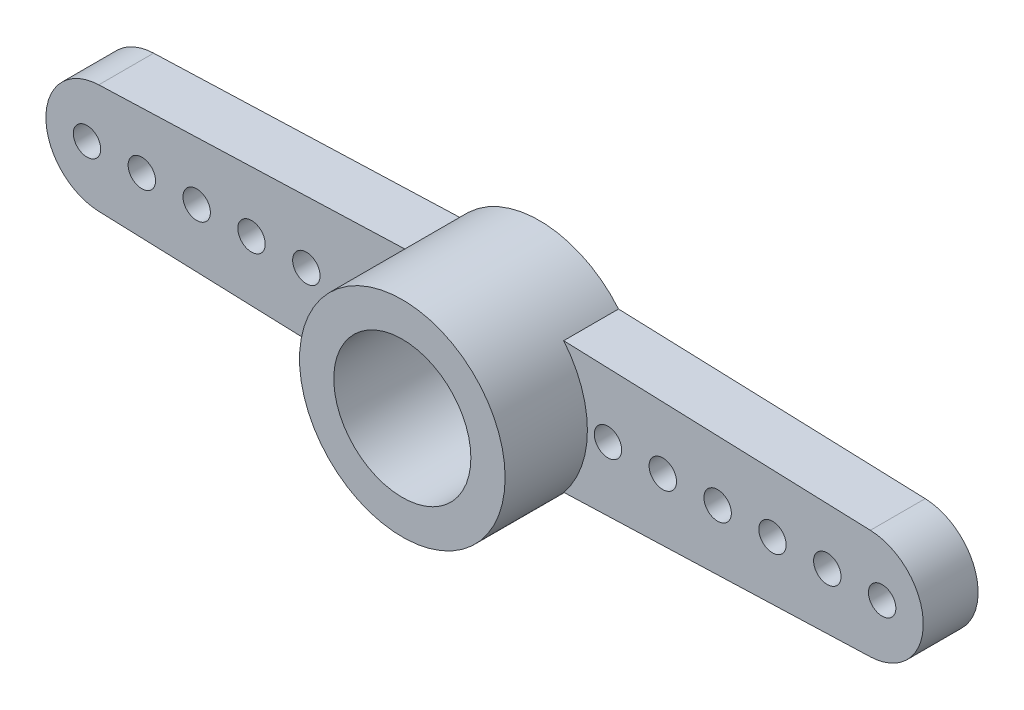
from build123d import *

# Parameters (mm, degrees)
EXTRUDE_3_DEPTH     = 2
EXTRUDE_3_2_DEPTH   = 2
SKETCH_2_R          = 3.75
SKETCH_2_R_2        = 2.5
EXTRUDE_5_DEPTH     = 3
SKETCH_3_R          = 3.75
SKETCH_3_R_2        = 2.5
EXTRUDE_6_DEPTH     = 2
SKETCH_4_R          = 0.5
CUT_EXTRUDE_1_DEPTH = 2
SKETCH_5_R          = 2.5
EXTRUDE_7_DEPTH     = 1
SKETCH_6_R          = 2.5
CUT_EXTRUDE_2_DEPTH = 0.5
SKETCH_7_R          = 1.25
CUT_EXTRUDE_3_DEPTH = 5


with BuildPart() as part:
    # Эскиз1 → Бобышка-Вытянуть3 (new body)
    with BuildSketch(Plane.XY):
        with BuildLine():
            ThreePointArc((-2.88547071, -2.395111434), (-3.527252129, -1.273182005), (-3.75, 0))
            ThreePointArc((-3.75, 0), (-3.527252129, 1.273182005), (-2.88547071, 2.395111434))
            Line((-2.88547071, 2.395111434), (-14.07082784, 1.998745461))
            ThreePointArc((-14.07082784, 1.998745461), (-16, 0), (-14.07082784, -1.998745461))
            Line((-14.07082784, -1.998745461), (-2.88547071, -2.395111434))
        make_face()
    extrude(amount=EXTRUDE_3_DEPTH)



with BuildPart() as body_2:
    # Эскиз1 → Extrude 3 2 (new body)
    with BuildSketch(Plane.XY):
        with BuildLine():
            Line((14.07082784, 1.998745461), (2.88547071, 2.395111434))
            ThreePointArc((2.88547071, 2.395111434), (3.75, 0), (2.88547071, -2.395111434))
            Line((2.88547071, -2.395111434), (14.07082784, -1.998745461))
            ThreePointArc((14.07082784, -1.998745461), (16, 0), (14.07082784, 1.998745461))
        make_face()
    extrude(amount=EXTRUDE_3_2_DEPTH)


with BuildPart() as body_3:
    # Эскиз2 → Бобышка-Вытянуть5 (new body)
    with BuildSketch(Plane.XY.offset(2)):
        Circle(SKETCH_2_R)
        Circle(SKETCH_2_R_2, mode=Mode.SUBTRACT)
    extrude(amount=EXTRUDE_5_DEPTH)


with BuildPart() as part_1:
    add(part.part)

    add(body_2.part)  # Бобышка-Вытянуть6 merges body 2

    add(body_3.part)  # Бобышка-Вытянуть6 merges body 3
    # Эскиз3 → Бобышка-Вытянуть6 (add)
    with BuildSketch(Plane(origin=(0, 0, 2), x_dir=(-1, 0, 0), z_dir=(0, 0, -1))):
        Circle(SKETCH_3_R)
        Circle(SKETCH_3_R_2, mode=Mode.SUBTRACT)
    extrude(amount=EXTRUDE_6_DEPTH)

    # Эскиз4 → Вырез-Вытянуть1 (cut)
    with BuildSketch(Plane(origin=(0, 0, 0), x_dir=(-1, 0, 0), z_dir=(0, 0, -1))):
        with Locations((-14.5, 0)):
            Circle(SKETCH_4_R)
        with Locations((-4.5, 0)):
            Circle(SKETCH_4_R)
        with Locations((-6.5, 0)):
            Circle(SKETCH_4_R)
        with Locations((-8.5, 0)):
            Circle(SKETCH_4_R)
        with Locations((-10.5, 0)):
            Circle(SKETCH_4_R)
        with Locations((-12.5, 0)):
            Circle(SKETCH_4_R)
        with Locations((4.5, 0)):
            Circle(SKETCH_4_R)
        with Locations((6.5, 0)):
            Circle(SKETCH_4_R)
        with Locations((8.5, 0)):
            Circle(SKETCH_4_R)
        with Locations((10.5, 0)):
            Circle(SKETCH_4_R)
        with Locations((12.5, 0)):
            Circle(SKETCH_4_R)
        with Locations((14.5, 0)):
            Circle(SKETCH_4_R)
    extrude(amount=-CUT_EXTRUDE_1_DEPTH, mode=Mode.SUBTRACT)

    # Эскиз5 → Бобышка-Вытянуть7 (add)
    with BuildSketch(Plane(origin=(0, 0, 0), x_dir=(-1, 0, 0), z_dir=(0, 0, -1))):
        Circle(SKETCH_5_R)
    extrude(amount=-EXTRUDE_7_DEPTH)

    # Эскиз6 → Вырез-Вытянуть2 (cut)
    with BuildSketch(Plane(origin=(0, 0, 0), x_dir=(-1, 0, 0), z_dir=(0, 0, -1))):
        Circle(SKETCH_6_R)
    extrude(amount=-CUT_EXTRUDE_2_DEPTH, mode=Mode.SUBTRACT)

    # Эскиз7 → Вырез-Вытянуть3 (cut)
    with BuildSketch(Plane(origin=(0, 0, 0.5), x_dir=(-1, 0, 0), z_dir=(0, 0, -1))):
        Circle(SKETCH_7_R)
    extrude(amount=-CUT_EXTRUDE_3_DEPTH, mode=Mode.SUBTRACT)


solid = part_1.part
